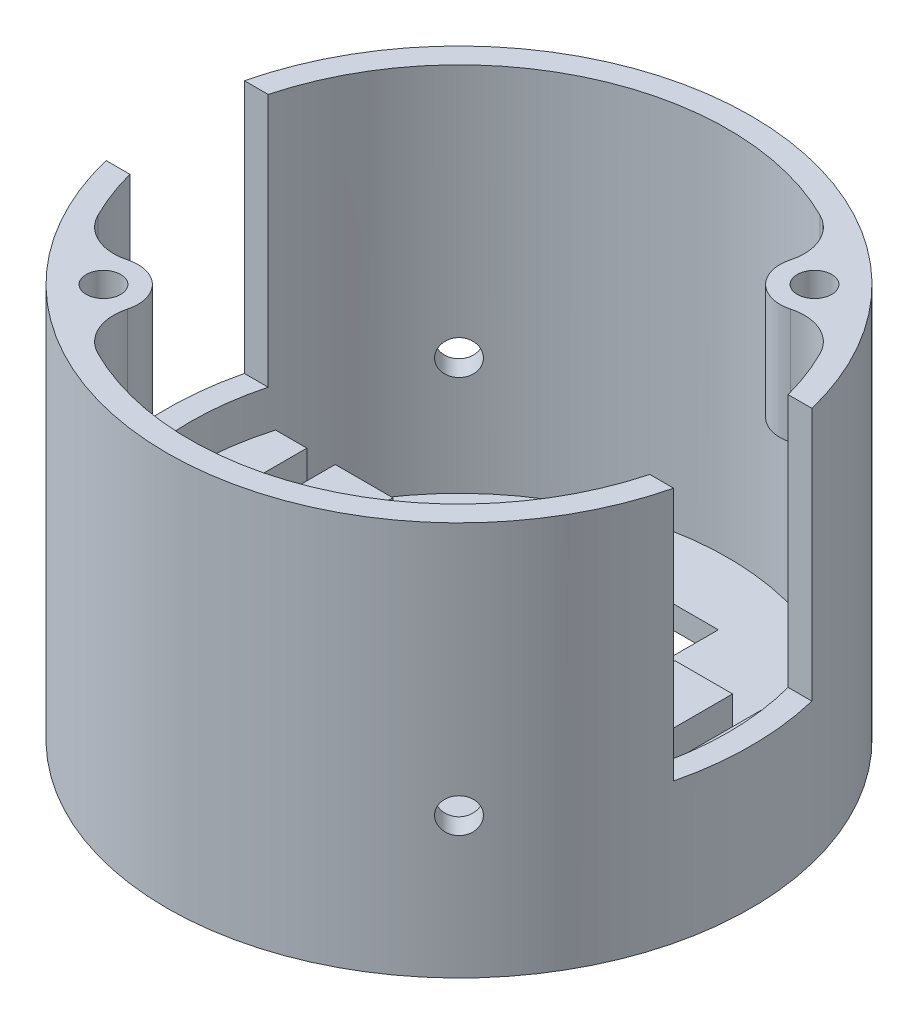
from build123d import *

# Parameters (mm, degrees)
SKETCH1_R           = 25.34
BOSS_EXTRUDE1_DEPTH = 34.2
SHELL1_T            = -2
SKETCH2_W           = 50.68
SKETCH2_H           = 12
CUT_EXTRUDE1_DEPTH  = 22
SKETCH3_W           = 5
SKETCH3_H           = 13
BOSS_EXTRUDE2_DEPTH = 6.8
SKETCH4_R           = 3
SKETCH4_R_2         = 1.5
BOSS_EXTRUDE3_DEPTH = 10
FILLET1_R           = 4
SKETCH6_R           = 1.5
CUT_EXTRUDE2_DEPTH  = 71.08683178
SKETCH7_W           = 10
SKETCH7_H           = 5
CUT_EXTRUDE3_DEPTH  = 49.177496994


with BuildPart() as part:
    # Sketch1 → Boss-Extrude1 (new body)
    with BuildSketch(Plane(origin=(0, 0, 0), x_dir=(1, 0, 0), z_dir=(0, 1, 0))):
        with Locations(Location((0, 0, 0), (0, 0, 270))):
            Circle(SKETCH1_R)
    extrude(amount=BOSS_EXTRUDE1_DEPTH)

    # Shell1
    shell1_openings = [part.faces().sort_by_distance(p)[0] for p in [
        (0, 34.2, 0),
    ]]
    offset(amount=SHELL1_T, openings=shell1_openings, kind=Kind.INTERSECTION)

    # Sketch2 → Cut-Extrude1 (cut)
    with BuildSketch(Plane(origin=(0, 34.2, 0), x_dir=(1, 0, 0), z_dir=(0, 1, 0))):
        Rectangle(SKETCH2_W, SKETCH2_H)
    extrude(amount=-CUT_EXTRUDE1_DEPTH, mode=Mode.SUBTRACT)

    # Sketch3 → Boss-Extrude2 (add)
    with BuildSketch(Plane(origin=(0, 2, 0), x_dir=(1, 0, 0), z_dir=(0, 1, 0))):
        with Locations((14.74, 0)):
            Rectangle(SKETCH3_W, SKETCH3_H)
        with BuildLine():
            Line((22.416636679, 6.5), (19.7, 6.5))
            Line((19.7, 6.5), (19.7, -6.5))
            Line((19.7, -6.5), (22.416636679, -6.5))
            ThreePointArc((22.416636679, -6.5), (23.34, 0), (22.416636679, 6.5))
        make_face()
        with BuildLine():
            Line((-19.7, -6.5), (-22.416636679, -6.5))
            ThreePointArc((-22.416636679, -6.5), (-23.34, 0), (-22.416636679, 6.5))
            Line((-22.416636679, 6.5), (-19.7, 6.5))
            Line((-19.7, 6.5), (-19.7, -6.5))
        make_face()
        with Locations((-14.74, 0)):
            Rectangle(SKETCH3_W, SKETCH3_H)
    extrude(amount=BOSS_EXTRUDE2_DEPTH)

    # Sketch4 → Boss-Extrude3 (add)
    with BuildSketch(Plane(origin=(0, 34.2, 0), x_dir=(1, 0, 0), z_dir=(0, 1, 0))):
        with Locations((15.423138364, 15.423138364)):
            Circle(SKETCH4_R)
        with Locations(Location((15.423138364, 15.423138364, 0), (0, 0, 270))):
            Circle(SKETCH4_R_2, mode=Mode.SUBTRACT)
        with Locations((-15.423138364, -15.423138364)):
            Circle(SKETCH4_R)
        with Locations(Location((-15.423138364, -15.423138364, 0), (0, 0, 270))):
            Circle(SKETCH4_R_2, mode=Mode.SUBTRACT)
    extrude(amount=-BOSS_EXTRUDE3_DEPTH)

    # Fillet1
    fillet1_edges = [part.edges().sort_by_distance(p)[0] for p in [
        (-18.28101213, 29.2, 14.510692455),
        (-14.510692455, 29.2, 18.28101213),
        (18.28101213, 29.2, -14.510692455),
        (14.510692455, 29.2, -18.28101213),
    ]]
    fillet(fillet1_edges, radius=FILLET1_R)

    # Sketch6 → Cut-Extrude2 (cut, through all)
    with BuildSketch(Plane(origin=(17.918085835, 34.2, 17.918085835), x_dir=(0.7071067811865487, 0, -0.7071067811865464), z_dir=(0.7071067811865464, 0, 0.7071067811865487))):
        with Locations((0, -22)):
            Circle(SKETCH6_R)
    extrude(amount=-CUT_EXTRUDE2_DEPTH, mode=Mode.SUBTRACT)

    # Sketch7 → Cut-Extrude3 (cut, through all)
    with BuildSketch(Plane(origin=(0, 2, 0), x_dir=(1, 0, 0), z_dir=(0, 1, 0))):
        with Locations((0, 15)):
            Rectangle(SKETCH7_W, SKETCH7_H)
        with Locations((0, -15)):
            Rectangle(SKETCH7_W, SKETCH7_H)
    extrude(amount=-CUT_EXTRUDE3_DEPTH, mode=Mode.SUBTRACT)


solid = part.part
